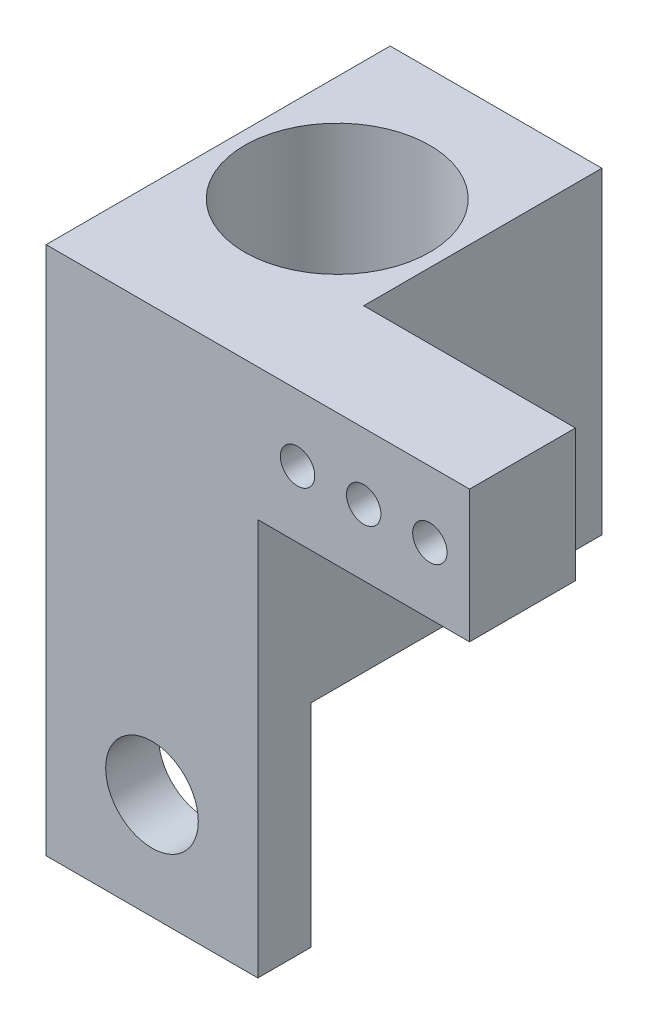
from build123d import *

# Parameters (mm, degrees)
BOSS_EXTRUDE1_DEPTH  = 2
SKETCH2_W            = 8
SKETCH2_H            = 8
BOSS_EXTRUDE2_DEPTH  = 2
SKETCH3_W            = 8
SKETCH3_H            = 8
BOSS_EXTRUDE3_DEPTH  = 8
SKETCH4_R            = 3.5
CUT_EXTRUDE1_DEPTH   = 10
CUT_EXTRUDE2_REACH   = 4
SKETCH5_R            = 0.65
CUT_EXTRUDE3_REACH   = 3
SKETCH6_R            = 0.65
SKETCH10_R           = 0.65
BOSS_EXTRUDE6_DEPTH  = 3
SKETCH11_W           = 8
SKETCH11_H           = 2
BOSS_EXTRUDE7_DEPTH  = 8
SKETCH12_R           = 1
CUT_EXTRUDE5_DEPTH   = 8
SKETCH13_W           = 8
SKETCH13_H           = 12
BOSS_EXTRUDE8_DEPTH  = 2
SKETCH14_W           = 8
SKETCH14_H           = 4
BOSS_EXTRUDE9_DEPTH  = 1
BOSS_EXTRUDE10_DEPTH = 2
SKETCH18_R           = 0.65
BOSS_EXTRUDE11_DEPTH = 4
CUT_EXTRUDE6_REACH   = 6
SKETCH19_R           = 0.65
CUT_EXTRUDE7_REACH   = 4
SKETCH20_R           = 1.75


with BuildPart() as part:
    # Sketch1 → Boss-Extrude1 (new body)
    with BuildSketch(Plane(origin=(0, 0, 0), x_dir=(1, 0, 0), z_dir=(0, 1, 0))):
        Polygon((-16, 0), (0, 0), (0, 1), (-8, 1), (-8, 8), (-16, 8), align=None)
    extrude(amount=BOSS_EXTRUDE1_DEPTH)

    # Sketch2 → Boss-Extrude2 (add)
    with BuildSketch(Plane(origin=(0, 2, 0), x_dir=(1, 0, 0), z_dir=(0, 1, 0))):
        with Locations((-12, 4)):
            Rectangle(SKETCH2_W, SKETCH2_H)
    extrude(amount=BOSS_EXTRUDE2_DEPTH)

    # Sketch3 → Boss-Extrude3 (add)
    with BuildSketch(Plane.XZ):
        with Locations((-12, -4)):
            Rectangle(SKETCH3_W, SKETCH3_H)
    extrude(amount=BOSS_EXTRUDE3_DEPTH)

    # Sketch4 → Cut-Extrude1 (cut)
    with BuildSketch(Plane(origin=(0, 4, 0), x_dir=(1, 0, 0), z_dir=(0, 1, 0))):
        with Locations((-12, 4)):
            Circle(SKETCH4_R)
    extrude(amount=-CUT_EXTRUDE1_DEPTH, mode=Mode.SUBTRACT)

    # Sketch5 → Cut-Extrude2 (cut, up to next)
    with BuildSketch(Plane(origin=(0, -6, 0), x_dir=(1, 0, 0), z_dir=(0, 1, 0)), mode=Mode.PRIVATE) as cut_extrude2_sk1:
        with Locations((-13.5, 4)):
            Circle(SKETCH5_R)
    cut_extrude2_tool1 = extrude(cut_extrude2_sk1.sketch, amount=-CUT_EXTRUDE2_REACH, mode=Mode.PRIVATE) & part.part
    add(cut_extrude2_tool1.solids().sort_by_distance((-13.5, -6, -4))[0], mode=Mode.SUBTRACT)
    # Sketch5 → Cut-Extrude2 (cut, up to next)
    with BuildSketch(Plane(origin=(0, -6, 0), x_dir=(1, 0, 0), z_dir=(0, 1, 0)), mode=Mode.PRIVATE) as cut_extrude2_sk2:
        with Locations((-10.5, 4)):
            Circle(SKETCH5_R)
    cut_extrude2_tool2 = extrude(cut_extrude2_sk2.sketch, amount=-CUT_EXTRUDE2_REACH, mode=Mode.PRIVATE) & part.part
    add(cut_extrude2_tool2.solids().sort_by_distance((-10.5, -6, -4))[0], mode=Mode.SUBTRACT)

    # Sketch6 → Cut-Extrude3 (cut, up to next)
    with BuildSketch(Plane(origin=(0, 0, -1), x_dir=(-1, 0, 0), z_dir=(0, 0, -1)), mode=Mode.PRIVATE) as cut_extrude3_sk1:
        with Locations((6.5, 1)):
            Circle(SKETCH6_R)
    cut_extrude3_tool1 = extrude(cut_extrude3_sk1.sketch, amount=-CUT_EXTRUDE3_REACH, mode=Mode.PRIVATE) & part.part
    add(cut_extrude3_tool1.solids().sort_by_distance((-6.5, 1, -1))[0], mode=Mode.SUBTRACT)
    # Sketch6 → Cut-Extrude3 (cut, up to next)
    with BuildSketch(Plane(origin=(0, 0, -1), x_dir=(-1, 0, 0), z_dir=(0, 0, -1)), mode=Mode.PRIVATE) as cut_extrude3_sk2:
        with Locations((4, 1)):
            Circle(SKETCH6_R)
    cut_extrude3_tool2 = extrude(cut_extrude3_sk2.sketch, amount=-CUT_EXTRUDE3_REACH, mode=Mode.PRIVATE) & part.part
    add(cut_extrude3_tool2.solids().sort_by_distance((-4, 1, -1))[0], mode=Mode.SUBTRACT)
    # Sketch6 → Cut-Extrude3 (cut, up to next)
    with BuildSketch(Plane(origin=(0, 0, -1), x_dir=(-1, 0, 0), z_dir=(0, 0, -1)), mode=Mode.PRIVATE) as cut_extrude3_sk3:
        with Locations((1.5, 1)):
            Circle(SKETCH6_R)
    cut_extrude3_tool3 = extrude(cut_extrude3_sk3.sketch, amount=-CUT_EXTRUDE3_REACH, mode=Mode.PRIVATE) & part.part
    add(cut_extrude3_tool3.solids().sort_by_distance((-1.5, 1, -1))[0], mode=Mode.SUBTRACT)

    # Sketch10 → Boss-Extrude6 (add)
    with BuildSketch(Plane.XY):
        Polygon((-8, 2), (-16, 2), (-16, -8), (-8, -8), (-8, 0), (0, 0), (0, 2), align=None)
        with Locations((-1.5, 1)):
            Circle(SKETCH10_R, mode=Mode.SUBTRACT)
        with Locations((-4, 1)):
            Circle(SKETCH10_R, mode=Mode.SUBTRACT)
        with Locations((-6.5, 1)):
            Circle(SKETCH10_R, mode=Mode.SUBTRACT)
    extrude(amount=BOSS_EXTRUDE6_DEPTH)

    # Sketch11 → Boss-Extrude7 (add)
    with BuildSketch(Plane.XZ.offset(8)):
        with Locations((-12, 2)):
            Rectangle(SKETCH11_W, SKETCH11_H)
    extrude(amount=BOSS_EXTRUDE7_DEPTH)

    # Sketch12 → Cut-Extrude5 (cut)
    with BuildSketch(Plane(origin=(0, 0, 1), x_dir=(-1, 0, 0), z_dir=(0, 0, -1))):
        with Locations((12, -12)):
            Circle(SKETCH12_R)
    extrude(amount=-CUT_EXTRUDE5_DEPTH, mode=Mode.SUBTRACT)

    # Sketch13 → Boss-Extrude8 (add)
    with BuildSketch(Plane(origin=(0, 0, -8), x_dir=(-1, 0, 0), z_dir=(0, 0, -1))):
        with Locations((12, -2)):
            Rectangle(SKETCH13_W, SKETCH13_H)
    extrude(amount=BOSS_EXTRUDE8_DEPTH)

    # Sketch14 → Boss-Extrude9 (add)
    with BuildSketch(Plane.XZ):
        with Locations((-4, 1)):
            Rectangle(SKETCH14_W, SKETCH14_H)
    extrude(amount=BOSS_EXTRUDE9_DEPTH)

    # Sketch15 → Boss-Extrude10 (add)
    with BuildSketch(Plane(origin=(0, 2, 0), x_dir=(1, 0, 0), z_dir=(0, 1, 0))):
        Polygon((-8, 0), (-8, 1), (0, 1), (0, -3), (-16, -3), (-16, 0), align=None)
    extrude(amount=BOSS_EXTRUDE10_DEPTH)

    # Sketch18 → Boss-Extrude11 (add)
    with BuildSketch(Plane(origin=(0, 0, -1), x_dir=(-1, 0, 0), z_dir=(0, 0, -1))):
        with Locations((1.5, 1)):
            Circle(SKETCH18_R)
        with Locations((4, 1)):
            Circle(SKETCH18_R)
        with Locations((6.5, 1)):
            Circle(SKETCH18_R)
    extrude(amount=-BOSS_EXTRUDE11_DEPTH)

    # Sketch19 → Cut-Extrude6 (cut, up to next)
    with BuildSketch(Plane(origin=(0, 0, -1), x_dir=(-1, 0, 0), z_dir=(0, 0, -1)), mode=Mode.PRIVATE) as cut_extrude6_sk1:
        with Locations((1.5, 1.5)):
            Circle(SKETCH19_R)
    cut_extrude6_tool1 = extrude(cut_extrude6_sk1.sketch, amount=-CUT_EXTRUDE6_REACH, mode=Mode.PRIVATE) & part.part
    add(cut_extrude6_tool1.solids().sort_by_distance((-1.5, 1.5, -1))[0], mode=Mode.SUBTRACT)
    # Sketch19 → Cut-Extrude6 (cut, up to next)
    with BuildSketch(Plane(origin=(0, 0, -1), x_dir=(-1, 0, 0), z_dir=(0, 0, -1)), mode=Mode.PRIVATE) as cut_extrude6_sk2:
        with Locations((4, 1.5)):
            Circle(SKETCH19_R)
    cut_extrude6_tool2 = extrude(cut_extrude6_sk2.sketch, amount=-CUT_EXTRUDE6_REACH, mode=Mode.PRIVATE) & part.part
    add(cut_extrude6_tool2.solids().sort_by_distance((-4, 1.5, -1))[0], mode=Mode.SUBTRACT)
    # Sketch19 → Cut-Extrude6 (cut, up to next)
    with BuildSketch(Plane(origin=(0, 0, -1), x_dir=(-1, 0, 0), z_dir=(0, 0, -1)), mode=Mode.PRIVATE) as cut_extrude6_sk3:
        with Locations((6.5, 1.5)):
            Circle(SKETCH19_R)
    cut_extrude6_tool3 = extrude(cut_extrude6_sk3.sketch, amount=-CUT_EXTRUDE6_REACH, mode=Mode.PRIVATE) & part.part
    add(cut_extrude6_tool3.solids().sort_by_distance((-6.5, 1.5, -1))[0], mode=Mode.SUBTRACT)

    # Sketch20 → Cut-Extrude7 (cut, up to next)
    with BuildSketch(Plane(origin=(0, 0, 1), x_dir=(-1, 0, 0), z_dir=(0, 0, -1)), mode=Mode.PRIVATE) as cut_extrude7_sk1:
        with Locations((12, -12)):
            Circle(SKETCH20_R)
    cut_extrude7_tool1 = extrude(cut_extrude7_sk1.sketch, amount=-CUT_EXTRUDE7_REACH, mode=Mode.PRIVATE) & part.part
    add(cut_extrude7_tool1.solids().sort_by_distance((-12, -12, 1))[0], mode=Mode.SUBTRACT)


solid = part.part
